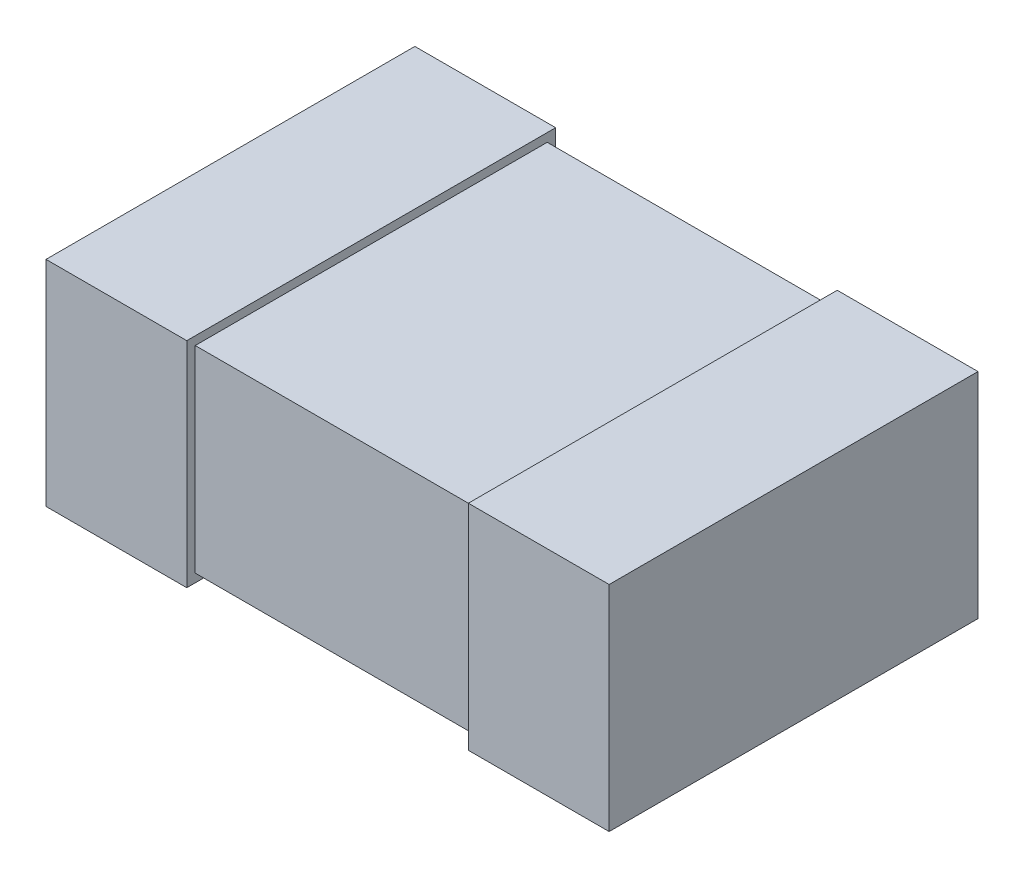
from build123d import *

# Parameters (mm, degrees)
SKETCH1_W           = 2
SKETCH1_H           = 1.25
EXTRUDE1_DEPTH      = 0.7
SKETCH2_W           = 0.5
SKETCH2_H           = 0.76
EXTRUDE2_DEPTH      = 0.655
EXTRUDE2_DEPTH_BACK = 0.655


with BuildPart() as part:
    # Sketch1 → Extrude1 (new body)
    with BuildSketch(Plane(origin=(0, 0, 0), x_dir=(1, 0, 0), z_dir=(0, 1, 0))):
        Rectangle(SKETCH1_W, SKETCH1_H)
    extrude(amount=EXTRUDE1_DEPTH)

    # Sketch2 → Extrude2 (add, two sides)
    with BuildSketch(Plane.XY) as extrude2_sk:
        with Locations((-0.75, 0.35)):
            Rectangle(SKETCH2_W, SKETCH2_H)
        with Locations((0.75, 0.35)):
            Rectangle(SKETCH2_W, SKETCH2_H)
    extrude(amount=EXTRUDE2_DEPTH)
    extrude(extrude2_sk.sketch, amount=-EXTRUDE2_DEPTH_BACK)


solid = part.part
